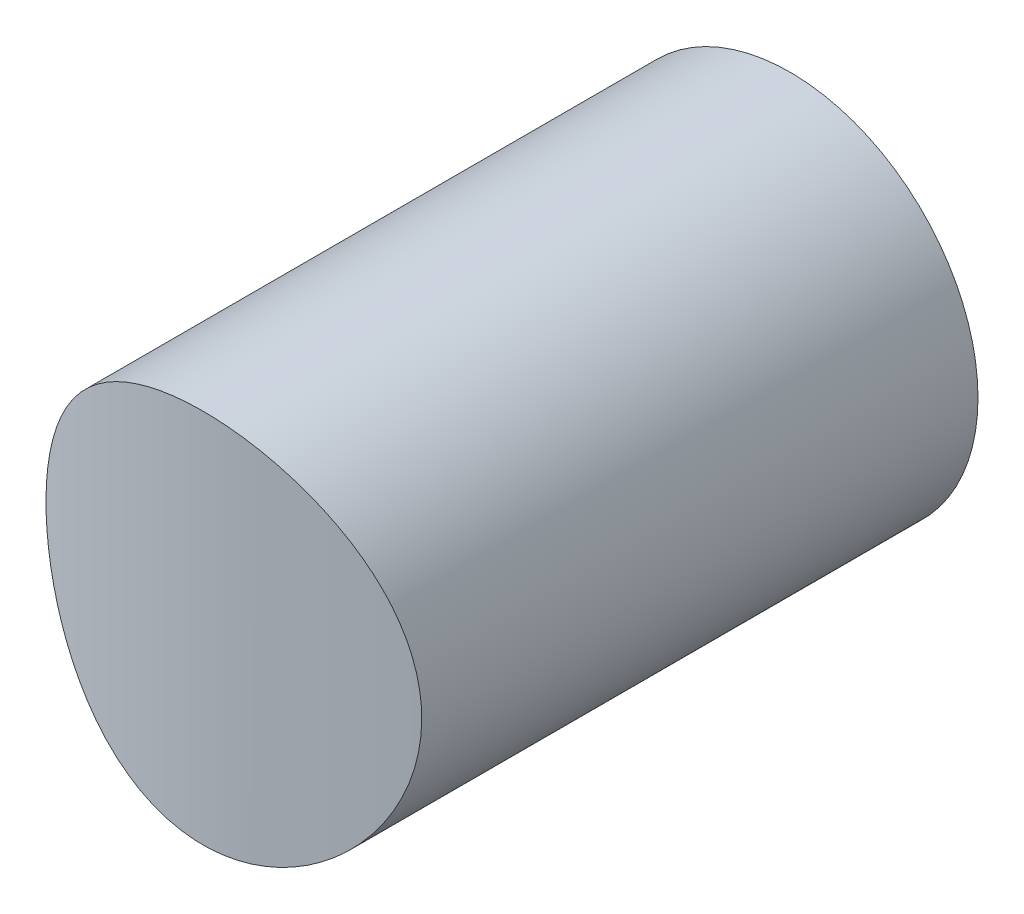
from build123d import *

# Parameters (mm, degrees)
SKETCH1_R               = 50.8
BOSS_EXTRUDE1_DEPTH     = 50.8
SKETCH2_W               = 101.6
SKETCH2_H               = 50.8
SKETCH2_R               = 16.256
CUT_EXTRUDE1_DEPTH      = 51.8
CUT_EXTRUDE1_DEPTH_BACK = 51.8
SKETCH3_R               = 16.256
CUT_EXTRUDE2_DEPTH      = 50.8


with BuildPart() as part:
    # Sketch1 → Boss-Extrude1 (new body)
    with BuildSketch(Plane(origin=(0, 0, 0), x_dir=(1, 0, 0), z_dir=(0, 1, 0))):
        Circle(SKETCH1_R)
    extrude(amount=BOSS_EXTRUDE1_DEPTH)

    # Sketch2 → Cut-Extrude1 (cut, two sides)
    with BuildSketch(Plane.XY) as cut_extrude1_sk:
        with Locations((0, 25.4)):
            Rectangle(SKETCH2_W, SKETCH2_H)
        with Locations((0, 25.4)):
            Circle(SKETCH2_R, mode=Mode.SUBTRACT)
    extrude(amount=CUT_EXTRUDE1_DEPTH, mode=Mode.SUBTRACT)
    extrude(cut_extrude1_sk.sketch, amount=-CUT_EXTRUDE1_DEPTH_BACK, mode=Mode.SUBTRACT)

    # Sketch3 → Cut-Extrude2 (cut)
    with BuildSketch(Plane.XY):
        with Locations((0, 25.4)):
            Circle(SKETCH3_R)
    extrude(amount=-CUT_EXTRUDE2_DEPTH, mode=Mode.SUBTRACT)


solid = part.part
